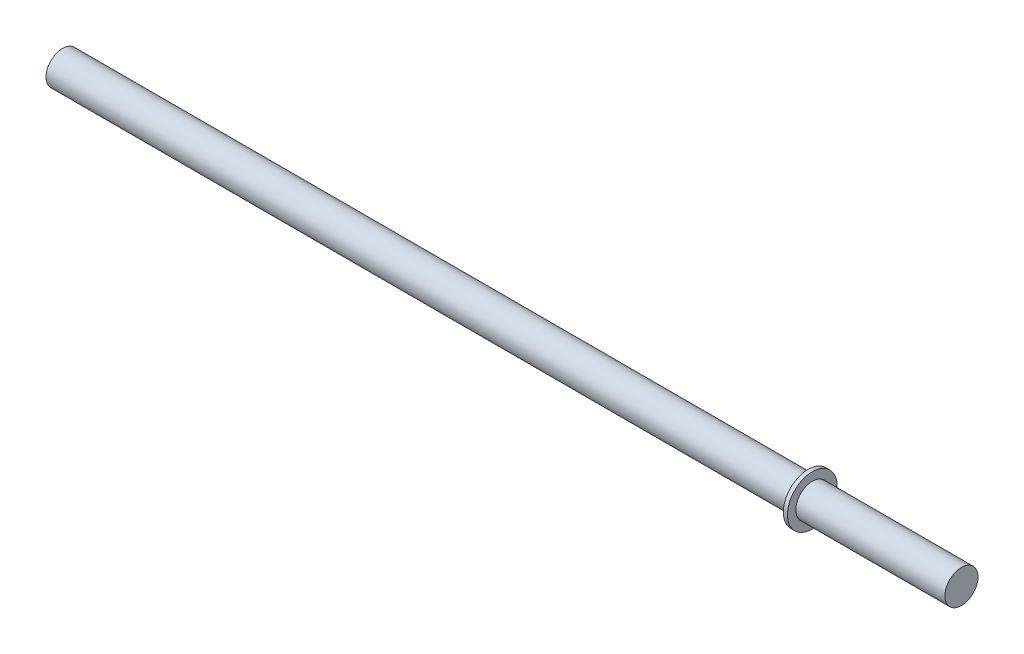
from build123d import *


with BuildPart() as part:
    # Szkic1 → Obrót1 (revolve)
    with BuildSketch(Plane.XY):
        Polygon((0, 0), (0, 2), (90, 2), (90, 3), (90.5, 3), (90.5, 2), (108.5, 2), (108.5, 0), align=None)
    revolve(axis=Axis((0, 0, 0), (1, 0, 0)))


solid = part.part
